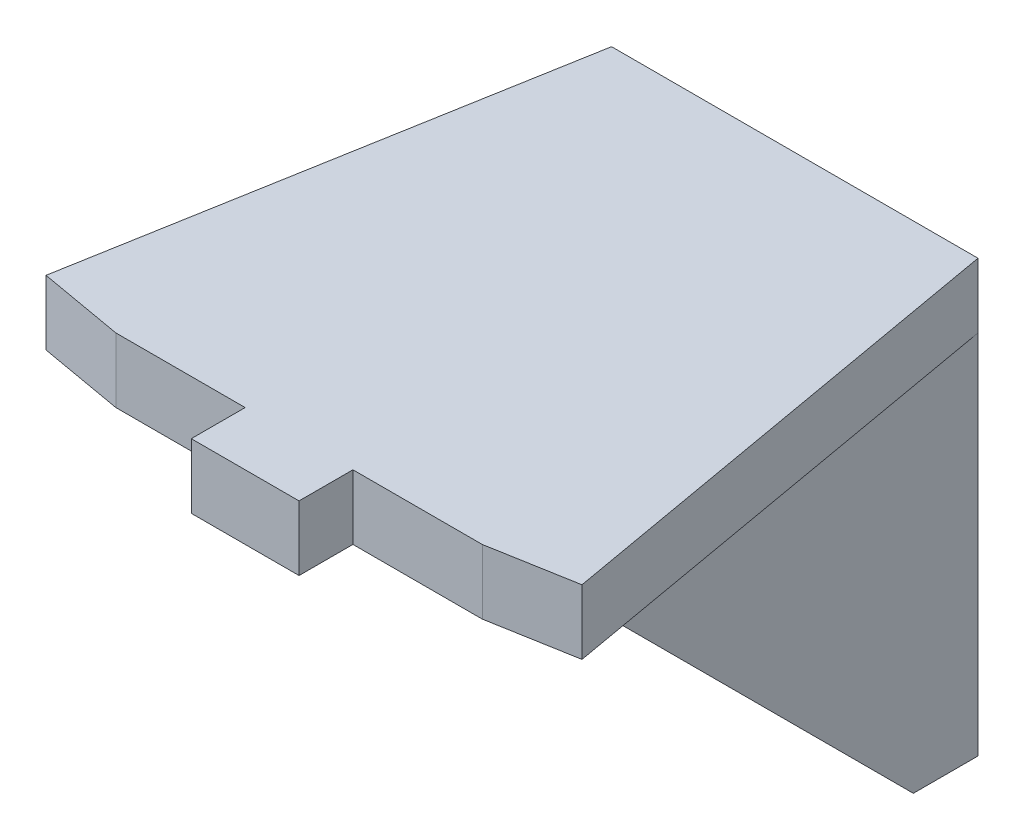
from build123d import *

# Parameters (mm, degrees)
BOSS_EXTRUDE1_DEPTH      = 8.5
SKETCH2_W                = 17
SKETCH2_H                = 17
CUT_EXTRUDE1_DEPTH       = 6
CUT_EXTRUDE2_REACH       = 5
RESSALTO_EXTRUS_O1_DEPTH = 3
RESSALTO_EXTRUS_O2_DEPTH = 3
ESBO_O3_W                = 5
ESBO_O3_H                = 3
RESSALTO_EXTRUS_O3_DEPTH = 2.5


with BuildPart() as part:
    # Sketch1 → Boss-Extrude1 (new body, symmetric)
    with BuildSketch(Plane(origin=(0, 0, 0), x_dir=(0, 0, -1), z_dir=(1, 0, 0))):
        Polygon((0, 0), (-20, 0), (-20, -3), (-11.5, -11.5), (-3, -20), (0, -20), align=None)
    extrude(amount=BOSS_EXTRUDE1_DEPTH, both=True)

    # Sketch2 → Cut-Extrude1 (cut, symmetric)
    with BuildSketch(Plane(origin=(0, 0, 0), x_dir=(0, 0, -1), z_dir=(1, 0, 0))):
        with Locations((-11.5, -11.5)):
            Rectangle(SKETCH2_W, SKETCH2_H)
    extrude(amount=CUT_EXTRUDE1_DEPTH, both=True, mode=Mode.SUBTRACT)

    # Sketch3 → Cut-Extrude2 (cut, up to next)
    with BuildSketch(Plane.XY.offset(3), mode=Mode.PRIVATE) as cut_extrude2_sk1:
        with BuildLine():
            Line((-3, -9), (-3, -12))
            ThreePointArc((-3, -12), (0, -15), (3, -12))
            Line((3, -12), (3, -9))
            ThreePointArc((3, -9), (0, -6), (-3, -9))
        make_face()
    cut_extrude2_tool1 = extrude(cut_extrude2_sk1.sketch, amount=-CUT_EXTRUDE2_REACH, mode=Mode.PRIVATE) & part.part
    add(cut_extrude2_tool1.solids().sort_by_distance((0, -10.5, 3))[0], mode=Mode.SUBTRACT)

    # Esboço1 → Ressalto-extrusão1 (add)
    with BuildSketch(Plane.XY.offset(20)):
        Polygon((-8.5, 0), (-8.5, -3), (-6, -3), (6, -3), (8.5, -3), (8.5, 0), align=None)
    extrude(amount=RESSALTO_EXTRUS_O1_DEPTH)

    # Esboço2 → Ressalto-extrusão2 (add)
    with BuildSketch(Plane(origin=(0, 0, 0), x_dir=(1, 0, 0), z_dir=(0, 1, 0))):
        Polygon((-8.5, 0), (-12.433231648, -22.306465139), (-8.5, -23), align=None)
    ressalto_extrus_o2 = extrude(amount=-RESSALTO_EXTRUS_O2_DEPTH)

    # Esboço3 → Ressalto-extrusão3 (add)
    with BuildSketch(Plane.XY.offset(23)):
        with Locations((0, -1.5)):
            Rectangle(ESBO_O3_W, ESBO_O3_H)
    extrude(amount=RESSALTO_EXTRUS_O3_DEPTH)

    # Espelhar1: Ressalto-extrusão2 across plane
    add(ressalto_extrus_o2.mirror(Plane(origin=(0, 0, 0), x_dir=(0, 0, 1), z_dir=(1, 0, 0))))


solid = part.part
